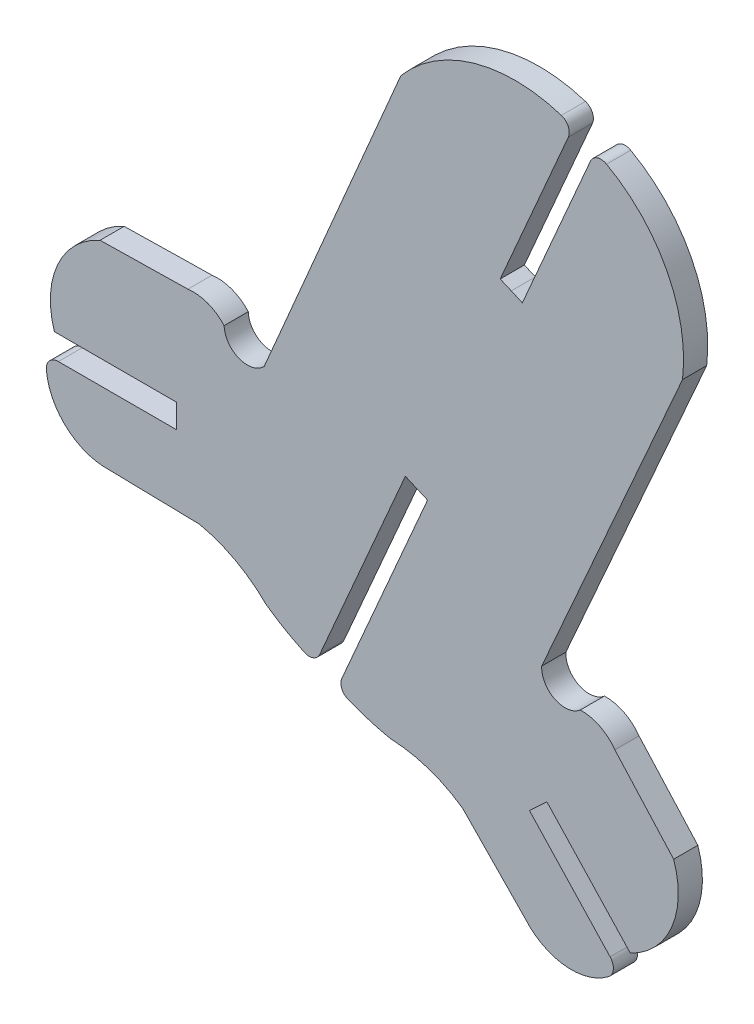
from build123d import *

# Parameters (mm, degrees)
BOSS_EXTRUDE1_DEPTH = 1.524


with BuildPart() as part:
    # Sketch1 → Boss-Extrude1 (new body)
    with BuildSketch(Plane.XY):
        with BuildLine():
            Line((-11.698031226, 1.301080189), (-17.241997575, 1.200259383))
            ThreePointArc((-17.241997575, 1.200259383), (-19.917117147, -1.466260827), (-20.124051829, -5.237702565))
            Line((-20.124051829, -5.237702565), (-12.408600231, -5.237702565))
            Line((-12.408600231, -5.237702565), (-12.408600231, -6.741954445))
            Line((-12.408600231, -6.741954445), (-19.871811516, -6.741954445))
            ThreePointArc((-19.871811516, -6.741954445), (-20.435206751, -6.990895181), (-20.630486437, -7.57506256))
            ThreePointArc((-20.630486437, -7.57506256), (-19.329359364, -10.115853363), (-16.636177401, -11.062067125))
            Line((-16.636177401, -11.062067125), (-10.972091682, -11.182579587))
            ThreePointArc((-10.972091682, -11.182579587), (-8.698171192, -12.023613454), (-6.754136813, -13.472331057))
            ThreePointArc((-6.754136813, -13.472331057), (-5.581948581, -14.227787409), (-4.346508881, -14.874647747))
            ThreePointArc((-4.346508881, -14.874647747), (-3.784346366, -14.895857379), (-3.377122413, -14.507726996))
            Line((-3.377122413, -14.507726996), (2.03023888, -2.061232355))
            Line((2.03023888, -2.061232355), (2.729092759, -2.364954689))
            Line((2.729092759, -2.364954689), (3.428024886, -2.668496912))
            Line((3.428024886, -2.668496912), (-1.97931368, -15.115001427))
            ThreePointArc((-1.97931368, -15.115001427), (-1.98510287, -15.677534117), (-1.585953772, -16.073963859))
            ThreePointArc((-1.585953772, -16.073963859), (-0.270018612, -16.535541807), (1.082127376, -16.876776006))
            ThreePointArc((1.082127376, -16.876776006), (3.467746446, -17.309065277), (5.634318126, -18.397191884))
            Line((5.634318126, -18.397191884), (9.587844362, -22.455026355))
            ThreePointArc((9.587844362, -22.455026355), (12.117419518, -23.777826074), (14.862522696, -22.994909661))
            ThreePointArc((14.862522696, -22.994909661), (15.156242938, -22.453509531), (14.953714903, -21.871815388))
            Line((14.953714903, -21.871815388), (9.860467214, -16.416693879))
            Line((9.860467214, -16.416693879), (10.959977394, -15.390121387))
            Line((10.959977394, -15.390121387), (16.22536578, -21.029614141))
            ThreePointArc((16.22536578, -21.029614141), (18.840822131, -18.304548485), (18.964246905, -14.529450993))
            Line((18.964246905, -14.529450993), (15.254476006, -10.408367691))
            ThreePointArc((15.254476006, -10.408367691), (14.298724728, -9.591322549), (13.07136856, -9.318155738))
            ThreePointArc((13.07136856, -9.318155738), (11.462041147, -9.532232913), (10.635341819, -8.134974174))
            Line((10.635341819, -8.134974174), (19.523278228, 11.967818074))
            ThreePointArc((19.523278228, 11.967818074), (18.552858543, 17.387639375), (14.725205948, 21.345574811))
            ThreePointArc((14.725205948, 21.345574811), (14.142053039, 21.397936165), (13.711309854, 21.001364186))
            Line((13.711309854, 21.001364186), (9.411697856, 11.104602687))
            Line((9.411697856, 11.104602687), (8.714639229, 11.412422878))
            Line((8.714639229, 11.412422878), (8.013937, 11.711856318))
            Line((8.013937, 11.711856318), (12.313567068, 21.608609967))
            ThreePointArc((12.313567068, 21.608609967), (12.30947588, 22.194094628), (11.873232067, 22.584607574))
            ThreePointArc((11.873232067, 22.584607574), (6.368068152, 22.681290418), (1.744271471, 19.691862119))
            Line((1.744271471, 19.691862119), (-6.884013371, -0.52373509))
            ThreePointArc((-6.884013371, -0.52373509), (-8.469497177, -0.873027031), (-9.411301698, 0.449382892))
            ThreePointArc((-9.411301698, 0.449382892), (-10.448574638, 1.160078409), (-11.698031226, 1.301080189))
        make_face()
    extrude(amount=BOSS_EXTRUDE1_DEPTH)


solid = part.part
